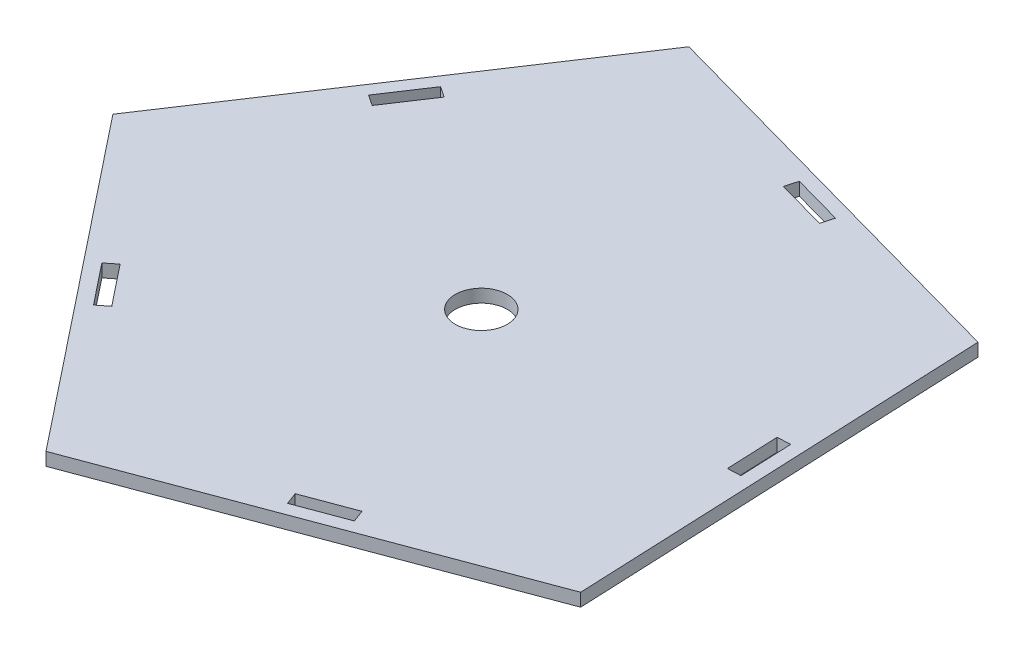
from build123d import *

# Parameters (mm, degrees)
BOSS_EXTRUDE1_DEPTH = 6.35
CUT_EXTRUDE1_DEPTH  = 7.35
SKETCH3_R           = 12.7
CUT_EXTRUDE2_DEPTH  = 7.35


with BuildPart() as part:
    # Sketch1 → Boss-Extrude1 (new body)
    with BuildSketch(Plane(origin=(0, 0, 0), x_dir=(1, 0, 0), z_dir=(0, 1, 0))):
        Polygon((-20.875255467, -32.826433561), (-29.617127229, 170.18543722), (-225.394276758, 224.605541248), (-337.649337625, 55.227144427), (-211.249631122, -103.874565796), align=None)
    extrude(amount=BOSS_EXTRUDE1_DEPTH)

    # Sketch2 → Cut-Extrude1 (cut, through all)
    with BuildSketch(Plane(origin=(0, 6.35, 0), x_dir=(1, 0, 0), z_dir=(0, 1, 0))):
        Polygon((-132.401350038, -60.892609465), (-108.604553081, -52.011592936), (-106.384298948, -57.960792175), (-130.181095905, -66.841808704), align=None)
        Polygon((-277.377537586, -10.429862968), (-261.577574273, -30.317576745), (-256.605645828, -26.367585917), (-272.405609141, -6.479872139), align=None)
        Polygon((-283.244673595, 125.822222384), (-277.951598695, 122.314251732), (-263.919716086, 143.486551334), (-269.212790987, 146.994521986), align=None)
        Polygon((-141.44240209, 194.678709813), (-116.970258399, 187.876196809), (-118.67088665, 181.758160887), (-143.143030341, 188.56067389), align=None)
        Polygon((-38.480800257, 80.821376768), (-32.136679295, 81.094560261), (-31.043945325, 55.718076413), (-37.388066287, 55.444892921), align=None)
    extrude(amount=-CUT_EXTRUDE1_DEPTH, mode=Mode.SUBTRACT)

    # Sketch3 → Cut-Extrude2 (cut, through all)
    with BuildSketch(Plane(origin=(0, 6.35, 0), x_dir=(1, 0, 0), z_dir=(0, 1, 0))):
        with Locations((-164.95712564, 62.663424707)):
            Circle(SKETCH3_R)
    extrude(amount=-CUT_EXTRUDE2_DEPTH, mode=Mode.SUBTRACT)


solid = part.part
